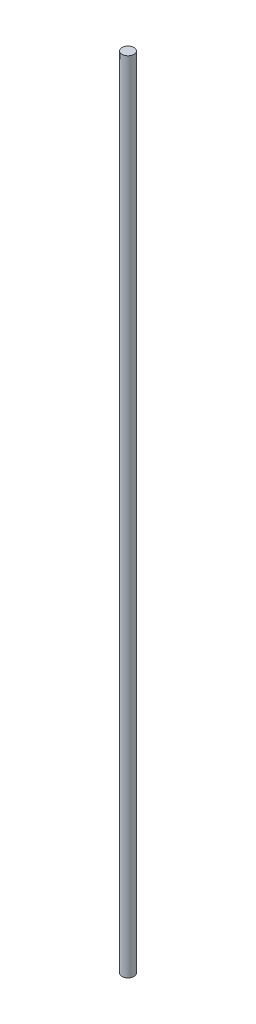
from build123d import *

# Parameters (mm, degrees)
SKETCH1_R           = 0.375
BOSS_EXTRUDE1_DEPTH = 50


with BuildPart() as part:
    # Sketch1 → Boss-Extrude1 (new body)
    with BuildSketch(Plane(origin=(0, 0, 0), x_dir=(1, 0, 0), z_dir=(0, 1, 0))):
        Circle(SKETCH1_R)
    extrude(amount=BOSS_EXTRUDE1_DEPTH)


solid = part.part
